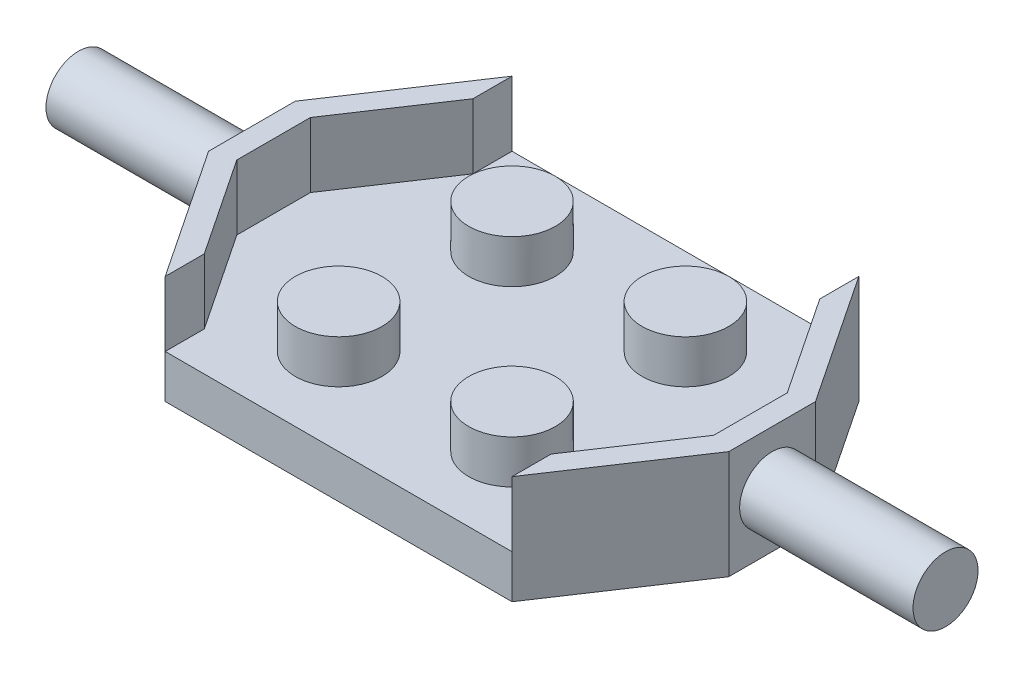
from build123d import *

# Parameters (mm, degrees)
BOSS_EXTRUDE1_DEPTH = 2
SKETCH2_R           = 2
BOSS_EXTRUDE2_DEPTH = 2
BOSS_EXTRUDE3_DEPTH = 3
SKETCH4_R           = 1.5
BOSS_EXTRUDE4_DEPTH = 8


with BuildPart() as part:
    # Sketch1 → Boss-Extrude1 (new body)
    with BuildSketch(Plane(origin=(0, 0, 0), x_dir=(1, 0, 0), z_dir=(0, 1, 0))):
        Polygon((-12, -2), (-12, 2), (-8, 8), (0, 8), (0, -8), (-8, -8), align=None)
    extrude(amount=BOSS_EXTRUDE1_DEPTH)

    # Sketch2 → Boss-Extrude2 (add)
    with BuildSketch(Plane(origin=(0, 2, 0), x_dir=(1, 0, 0), z_dir=(0, 1, 0))):
        with Locations((-4, 4)):
            Circle(SKETCH2_R)
        with Locations((-4, -4)):
            Circle(SKETCH2_R)
    extrude(amount=BOSS_EXTRUDE2_DEPTH)

    # Sketch3 → Boss-Extrude3 (add)
    with BuildSketch(Plane(origin=(0, 2, 0), x_dir=(1, 0, 0), z_dir=(0, 1, 0))):
        Polygon((-12, -2), (-8, -8), (-8, -6.197224362), (-11, -1.697224362), (-11, 1.697224362), (-8, 6.197224362), (-8, 8), (-12, 2), align=None)
    extrude(amount=BOSS_EXTRUDE3_DEPTH)

    # Sketch4 → Boss-Extrude4 (add)
    with BuildSketch(Plane.ZY.offset(12)):
        with Locations((0, 2.5)):
            Circle(SKETCH4_R)
    extrude(amount=BOSS_EXTRUDE4_DEPTH)

    # Mirror2: part across plane


with BuildPart() as part_1:
    add(part.part)
    add(part.part.mirror(Plane(origin=(0, 0, 0), x_dir=(0, 0, 1), z_dir=(1, 0, 0))))


solid = part_1.part
